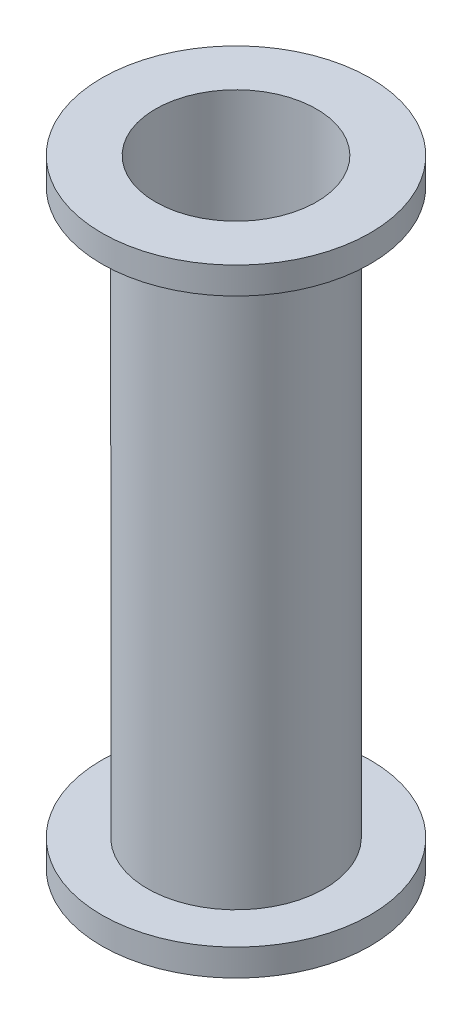
from build123d import *

# Parameters (mm, degrees)
SKETCH2_R            = 41.91
SKETCH2_R_2          = 38.1
BASE_CYLINDER_DEPTH  = 292.1
SKETCH3_R            = 63.5
SKETCH3_R_2          = 38.1
AFT_FLANGE_DEPTH     = 12.7
SKETCH4_R            = 63.5
SKETCH4_R_2          = 38.1
FORWARD_FLANGE_DEPTH = 12.7


with BuildPart() as part:
    # Sketch2 → Base Cylinder (new body)
    with BuildSketch(Plane(origin=(0, 0, 0), x_dir=(1, 0, 0), z_dir=(0, 1, 0))):
        Circle(SKETCH2_R)
        Circle(SKETCH2_R_2, mode=Mode.SUBTRACT)
    extrude(amount=BASE_CYLINDER_DEPTH)

    # Sketch3 → Aft Flange (add)
    with BuildSketch(Plane.XZ):
        Circle(SKETCH3_R)
        Circle(SKETCH3_R_2, mode=Mode.SUBTRACT)
    extrude(amount=-AFT_FLANGE_DEPTH)

    # Sketch4 → Forward Flange (add)
    with BuildSketch(Plane(origin=(0, 292.1, 0), x_dir=(1, 0, 0), z_dir=(0, 1, 0))):
        Circle(SKETCH4_R)
        Circle(SKETCH4_R_2, mode=Mode.SUBTRACT)
    extrude(amount=-FORWARD_FLANGE_DEPTH)


solid = part.part
